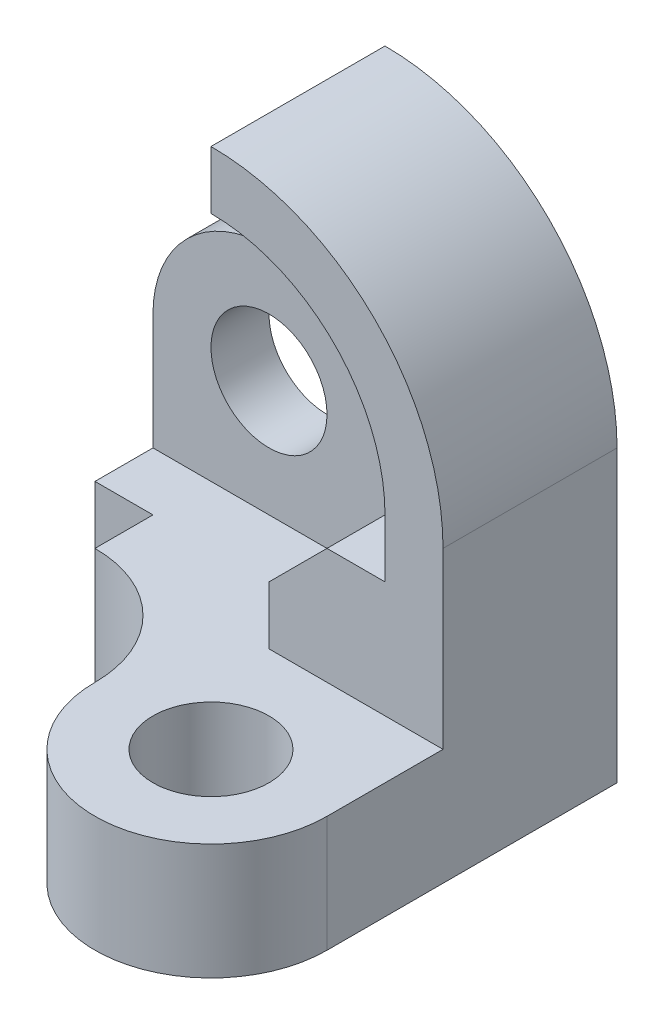
from build123d import *

# Parameters (mm, degrees)
BOSS_EXTRUDE1_DEPTH = 30
SKETCH2_R           = 10
BOSS_EXTRUDE2_DEPTH = 10
SKETCH3_W           = 70
SKETCH3_H           = 20
BOSS_EXTRUDE3_DEPTH = 70
CUT_EXTRUDE1_DEPTH  = 50
SKETCH6_R           = 10
CUT_EXTRUDE2_DEPTH  = 50


with BuildPart() as part:
    # Sketch1 → Boss-Extrude1 (new body)
    with BuildSketch(Plane.XY):
        with BuildLine():
            Line((0, 30), (0, 40))
            ThreePointArc((0, 40), (28.284271247, 28.284271247), (40, 0))
            Line((40, 0), (40, -30))
            Line((40, -30), (10, -30))
            Line((10, -30), (10, -20))
            Line((10, -20), (20, -10))
            Line((20, -10), (30, -10))
            Line((30, -10), (30, 0))
            ThreePointArc((30, 0), (21.213203436, 21.213203436), (0, 30))
        make_face()
    extrude(amount=BOSS_EXTRUDE1_DEPTH)

    # Sketch2 → Boss-Extrude2 (add)
    with BuildSketch(Plane.XY):
        with BuildLine():
            Line((0, 40), (0, 10))
            Line((0, 10), (-10, 10))
            ThreePointArc((-10, 10), (-24.142135624, 4.142135624), (-30, -10))
            Line((-30, -10), (-30, -50))
            Line((-30, -50), (40, -50))
            Line((40, -50), (40, 0))
            ThreePointArc((40, 0), (28.284271247, 28.284271247), (0, 40))
        make_face()
        with Locations((-10, -10)):
            Circle(SKETCH2_R, mode=Mode.SUBTRACT)
    extrude(amount=BOSS_EXTRUDE2_DEPTH)

    # Sketch3 → Boss-Extrude3 (add)
    with BuildSketch(Plane.XY.offset(10)):
        with Locations((5, -40)):
            Rectangle(SKETCH3_W, SKETCH3_H)
    extrude(amount=BOSS_EXTRUDE3_DEPTH)

    # Sketch4 → Cut-Extrude1 (cut)
    with BuildSketch(Plane(origin=(0, -30, 0), x_dir=(1, 0, 0), z_dir=(0, 1, 0))):
        with BuildLine():
            Line((-20, -30), (-20, -20))
            Line((-20, -20), (-30, -20))
            Line((-30, -20), (-30, -80))
            Line((-30, -80), (40, -80))
            Line((40, -80), (40, -50))
            ThreePointArc((40, -50), (20, -70), (0, -50))
            ThreePointArc((0, -50), (-5.857864376, -35.857864376), (-20, -30))
        make_face()
    extrude(amount=-CUT_EXTRUDE1_DEPTH, mode=Mode.SUBTRACT)

    # Sketch6 → Cut-Extrude2 (cut)
    with BuildSketch(Plane(origin=(0, -30, 0), x_dir=(1, 0, 0), z_dir=(0, 1, 0))):
        with Locations((20, -50)):
            Circle(SKETCH6_R)
    extrude(amount=-CUT_EXTRUDE2_DEPTH, mode=Mode.SUBTRACT)


solid = part.part
